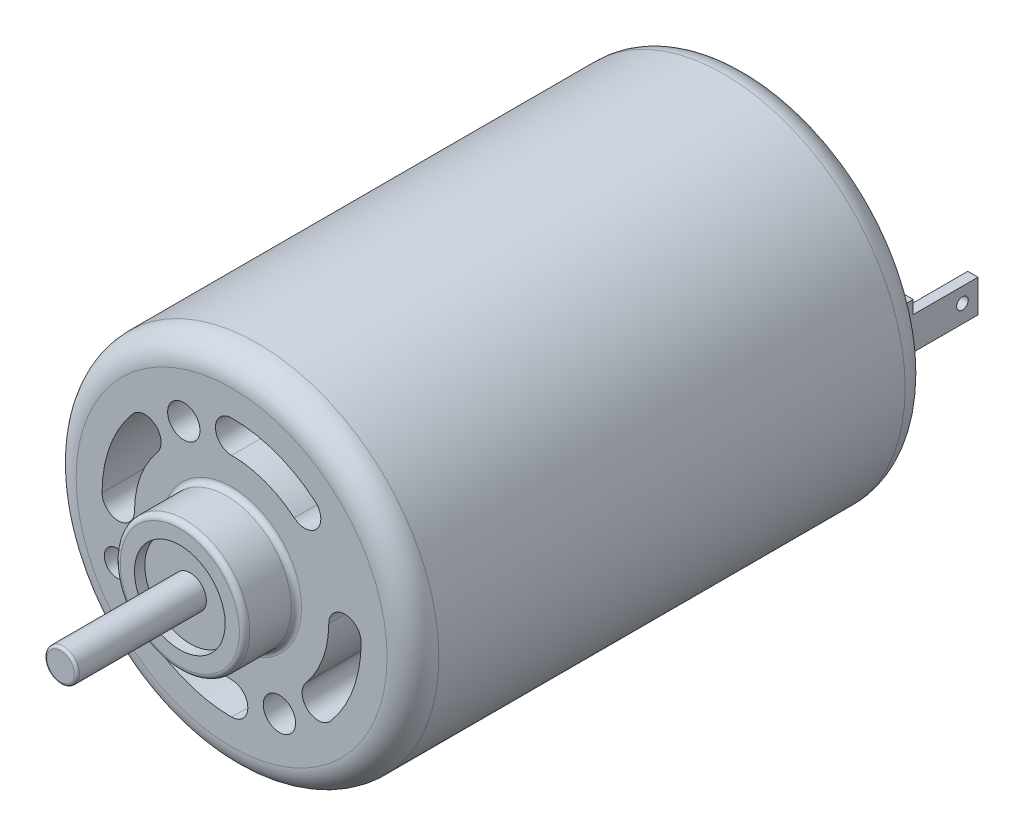
from build123d import *

# Parameters (mm, degrees)
SKETCH1_R           = 17.78
BOSS_EXTRUDE1_DEPTH = 50.8
SKETCH2_R           = 6.35
BOSS_EXTRUDE2_DEPTH = 5.08
FILLET1_R           = 0.508
SKETCH3_R           = 4.445
CUT_EXTRUDE1_DEPTH  = 1.016
FILLET2_R           = 2.54
SKETCH4_R           = 6.35
BOSS_EXTRUDE3_DEPTH = 2.54
FILLET3_R           = 1.27
SKETCH5_R           = 1.5875
BOSS_EXTRUDE4_DEPTH = 1.524
FILLET4_R           = 0.254
SKETCH6_R           = 1.5875
BOSS_EXTRUDE5_DEPTH = 12.7
FILLET5_R           = 0.254
SKETCH7_R           = 1.5875
SKETCH7_R_2         = 1.27
CUT_EXTRUDE2_DEPTH  = 25.4
SKETCH8_W           = 2.8575
SKETCH8_H           = 5.842
BOSS_EXTRUDE6_DEPTH = 1.905
SKETCH9_W           = 0.998982
SKETCH9_H           = 3.2045148
BOSS_EXTRUDE7_DEPTH = 6.35
SKETCH10_R          = 0.569556052
CUT_EXTRUDE3_DEPTH  = 32.90875


with BuildPart() as part:
    # Sketch1 → Boss-Extrude1 (new body)
    with BuildSketch(Plane.XY):
        Circle(SKETCH1_R)
    extrude(amount=BOSS_EXTRUDE1_DEPTH)

    # Sketch2 → Boss-Extrude2 (add)
    with BuildSketch(Plane.XY.offset(50.8)):
        Circle(SKETCH2_R)
    extrude(amount=BOSS_EXTRUDE2_DEPTH)

    # Fillet1
    fillet1_edges = [part.edges().sort_by_distance(p)[0] for p in [
        (-6.35, 0, 50.8),
        (-6.35, 0, 55.88),
    ]]
    fillet(fillet1_edges, radius=FILLET1_R)

    # Sketch3 → Cut-Extrude1 (cut)
    with BuildSketch(Plane.XY.offset(55.88)):
        Circle(SKETCH3_R)
    extrude(amount=-CUT_EXTRUDE1_DEPTH, mode=Mode.SUBTRACT)

    # Fillet2
    fillet2_edges = [part.edges().sort_by_distance(p)[0] for p in [
        (-17.78, 0, 0),
        (-17.78, 0, 50.8),
    ]]
    fillet(fillet2_edges, radius=FILLET2_R)

    # Sketch6 → Boss-Extrude5 (add)
    with BuildSketch(Plane.XY.offset(54.864)):
        Circle(SKETCH6_R)
    extrude(amount=BOSS_EXTRUDE5_DEPTH)

    # Fillet5
    fillet5_edges = [part.edges().sort_by_distance(p)[0] for p in [
        (-1.5875, 0, 67.564),
    ]]
    fillet(fillet5_edges, radius=FILLET5_R)

    # Sketch7 → Cut-Extrude2 (cut)
    with BuildSketch(Plane.XY.offset(50.8)):
        with Locations((-4.687371404, 10.075525077)):
            Circle(SKETCH7_R)
        with Locations((-11.218854293, -5.240573882)):
            Circle(SKETCH7_R_2)
        with Locations((4.687371404, -10.075525077)):
            Circle(SKETCH7_R)
        with BuildLine():
            ThreePointArc((8.180723627, 9.714204082), (4.354285714, 11.930221956), (0, 12.7))
            ThreePointArc((0, 12.7), (-1.5875, 11.1125), (0, 9.525))
            ThreePointArc((0, 9.525), (3.265714286, 8.947666467), (6.13554272, 7.285653061))
            ThreePointArc((6.13554272, 7.285653061), (8.372408684, 7.477338118), (8.180723627, 9.714204082))
        make_face()
        with BuildLine():
            ThreePointArc((12.7, 0), (11.1125, 1.5875), (9.525, 0))
            ThreePointArc((9.525, 0), (8.947666467, -3.265714286), (7.285653061, -6.13554272))
            ThreePointArc((7.285653061, -6.13554272), (7.477338118, -8.372408684), (9.714204082, -8.180723627))
            ThreePointArc((9.714204082, -8.180723627), (11.930221956, -4.354285714), (12.7, 0))
        make_face()
        with BuildLine():
            ThreePointArc((0, -12.7), (1.5875, -11.1125), (0, -9.525))
            ThreePointArc((0, -9.525), (-3.265714286, -8.947666467), (-6.13554272, -7.285653061))
            ThreePointArc((-6.13554272, -7.285653061), (-8.372408684, -7.477338118), (-8.180723627, -9.714204082))
            ThreePointArc((-8.180723627, -9.714204082), (-4.354285714, -11.930221956), (0, -12.7))
        make_face()
        with BuildLine():
            ThreePointArc((-12.7, 0), (-11.1125, -1.5875), (-9.525, 0))
            ThreePointArc((-9.525, 0), (-8.947666467, 3.265714286), (-7.285653061, 6.13554272))
            ThreePointArc((-7.285653061, 6.13554272), (-7.477338118, 8.372408684), (-9.714204082, 8.180723627))
            ThreePointArc((-9.714204082, 8.180723627), (-11.930221956, 4.354285714), (-12.7, 0))
        make_face()
    extrude(amount=-CUT_EXTRUDE2_DEPTH, mode=Mode.SUBTRACT)

    # Sketch8 → Boss-Extrude6 (add)
    with BuildSketch(Plane(origin=(0, 0, 0), x_dir=(-1, 0, 0), z_dir=(0, 0, -1))):
        with Locations((12.7, 0.55661423)):
            Rectangle(SKETCH8_W, SKETCH8_H)
        with Locations((-12.7, 0.55661423)):
            Rectangle(SKETCH8_W, SKETCH8_H)
    extrude(amount=BOSS_EXTRUDE6_DEPTH)

    # Sketch9 → Boss-Extrude7 (add)
    with BuildSketch(Plane(origin=(0, 0, -1.905), x_dir=(-1, 0, 0), z_dir=(0, 0, -1))):
        with Locations((13.629259, 0.58892103)):
            Rectangle(SKETCH9_W, SKETCH9_H)
        with Locations((-13.629259, 0.58892103)):
            Rectangle(SKETCH9_W, SKETCH9_H)
    extrude(amount=BOSS_EXTRUDE7_DEPTH)

    # Sketch10 → Cut-Extrude3 (cut, through all)
    with BuildSketch(Plane(origin=(14.12875, 0, 0), x_dir=(0, 0, -1), z_dir=(1, 0, 0))):
        with Locations((6.731, 0.73067843)):
            Circle(SKETCH10_R)
    extrude(amount=-CUT_EXTRUDE3_DEPTH, mode=Mode.SUBTRACT)


with BuildPart() as body_2:
    # Sketch4 → Boss-Extrude3 (new body)
    with BuildSketch(Plane(origin=(0, 0, 0), x_dir=(-1, 0, 0), z_dir=(0, 0, -1))):
        Circle(SKETCH4_R)
    extrude(amount=BOSS_EXTRUDE3_DEPTH)

    # Fillet3
    fillet3_edges = [body_2.edges().sort_by_distance(p)[0] for p in [
        (6.35, 0, -2.54),
    ]]
    fillet(fillet3_edges, radius=FILLET3_R)

    # Sketch5 → Boss-Extrude4 (add)
    with BuildSketch(Plane(origin=(0, 0, -2.54), x_dir=(-1, 0, 0), z_dir=(0, 0, -1))):
        Circle(SKETCH5_R)
    extrude(amount=BOSS_EXTRUDE4_DEPTH)

    # Fillet4
    fillet4_edges = [body_2.edges().sort_by_distance(p)[0] for p in [
        (1.5875, 0, -4.064),
    ]]
    fillet(fillet4_edges, radius=FILLET4_R)


solid = Compound([part.part, body_2.part])
